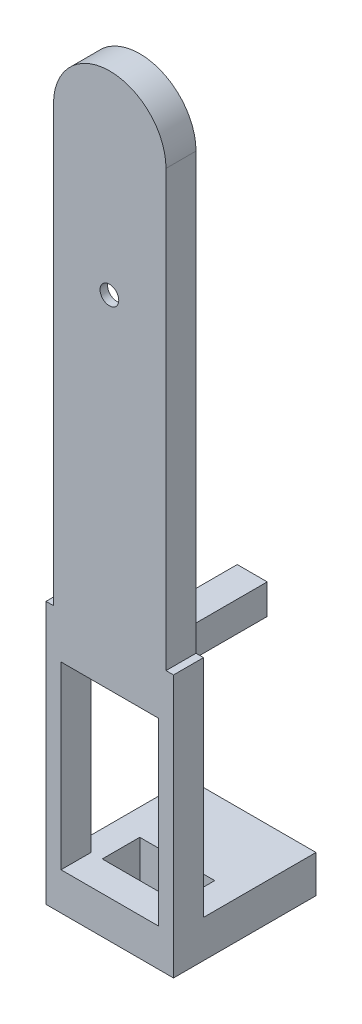
from build123d import *

# Parameters (mm, degrees)
EXTRUDE_1_DEPTH     = 4
SKETCH_6_W          = 17
SKETCH_6_H          = 35
EXTRUDE_2_DEPTH     = 4
SKETCH_7_W          = 13
SKETCH_7_H          = 24
CUT_EXTRUDE_3_DEPTH = 12.1
SKETCH_8_W          = 4
SKETCH_8_H          = 4
SKETCH_8_R          = 1.175
EXTRUDE_3_DEPTH     = 15
EXTRUDE_4_DEPTH     = 5
SKETCH_10_R         = 1.175
CUT_EXTRUDE_4_DEPTH = 12.7
CUT_EXTRUDE_6_DEPTH = 3
SKETCH_13_R         = 1.25
CUT_EXTRUDE_7_DEPTH = 13


with BuildPart() as part:
    # 草圖1 → 填料-伸長1 (new body)
    with BuildSketch(Plane.XY):
        with BuildLine():
            Line((7.5, 0), (7.5, 58))
            ThreePointArc((7.5, 58), (0, 65.5), (-7.5, 58))
            Line((-7.5, 58), (-7.5, 0))
            Line((-7.5, 0), (7.5, 0))
        make_face()
    extrude(amount=EXTRUDE_1_DEPTH)

    # 草圖6 → 填料-伸長2 (add)
    with BuildSketch(Plane.XY):
        with Locations((0, -17.5)):
            Rectangle(SKETCH_6_W, SKETCH_6_H)
    extrude(amount=EXTRUDE_2_DEPTH)

    # 草圖7 → 除料-伸長3 (cut)
    with BuildSketch(Plane.XY):
        with Locations((0, -18)):
            Rectangle(SKETCH_7_W, SKETCH_7_H)
    extrude(amount=CUT_EXTRUDE_3_DEPTH, mode=Mode.SUBTRACT)

    # 草圖8 → 填料-伸長3 (add)
    with BuildSketch(Plane.XY):
        with Locations((0, -4)):
            Rectangle(SKETCH_8_W, SKETCH_8_H)
        with Locations((0, -4)):
            Circle(SKETCH_8_R, mode=Mode.SUBTRACT)
    extrude(amount=-EXTRUDE_3_DEPTH)

    # 草圖9 → 填料-伸長4 (add)
    with BuildSketch(Plane(origin=(0, -35, 0), x_dir=(1, 0, 0), z_dir=(0, 1, 0))):
        Polygon((-8.5, 0), (-5, 0), (-5, 5), (5, 5), (5, 0), (8.5, 0), (8.5, 15), (-8.5, 15), align=None)
    extrude(amount=EXTRUDE_4_DEPTH)

    # 草圖10 → 除料-伸長4 (cut)
    with BuildSketch(Plane(origin=(0, 0, -15), x_dir=(-1, 0, 0), z_dir=(0, 0, -1))):
        with Locations((0, -32.5)):
            Circle(SKETCH_10_R)
    extrude(amount=-CUT_EXTRUDE_4_DEPTH, mode=Mode.SUBTRACT)

    # 草圖11 → 除料-伸長6 (cut)
    with BuildSketch(Plane(origin=(0, 0, 0), x_dir=(-1, 0, 0), z_dir=(0, 0, -1))):
        with BuildLine():
            Line((5.049815955, 39.60423521), (2.470722118, 21.775887923))
            ThreePointArc((2.470722118, 21.775887923), (0.036377399, 19.816776136), (-2.09239788, 22.10423521))
            Line((-2.09239788, 22.10423521), (-4.950184045, 39.60423521))
            Line((-4.950184045, 39.60423521), (-2.082979546, 57.10423521))
            ThreePointArc((-2.082979546, 57.10423521), (0.200975521, 59.388190276), (2.484930588, 57.10423521))
            Line((2.484930588, 57.10423521), (5.049815955, 39.60423521))
        make_face()
    extrude(amount=-CUT_EXTRUDE_6_DEPTH, mode=Mode.SUBTRACT)

    # 草圖13 → 除料-伸長7 (cut)
    with BuildSketch(Plane(origin=(0, 0, 0), x_dir=(-1, 0, 0), z_dir=(0, 0, -1))):
        with Locations((0.049815955, 39.60423521)):
            Circle(SKETCH_13_R)
    extrude(amount=-CUT_EXTRUDE_7_DEPTH, mode=Mode.SUBTRACT)


solid = part.part
